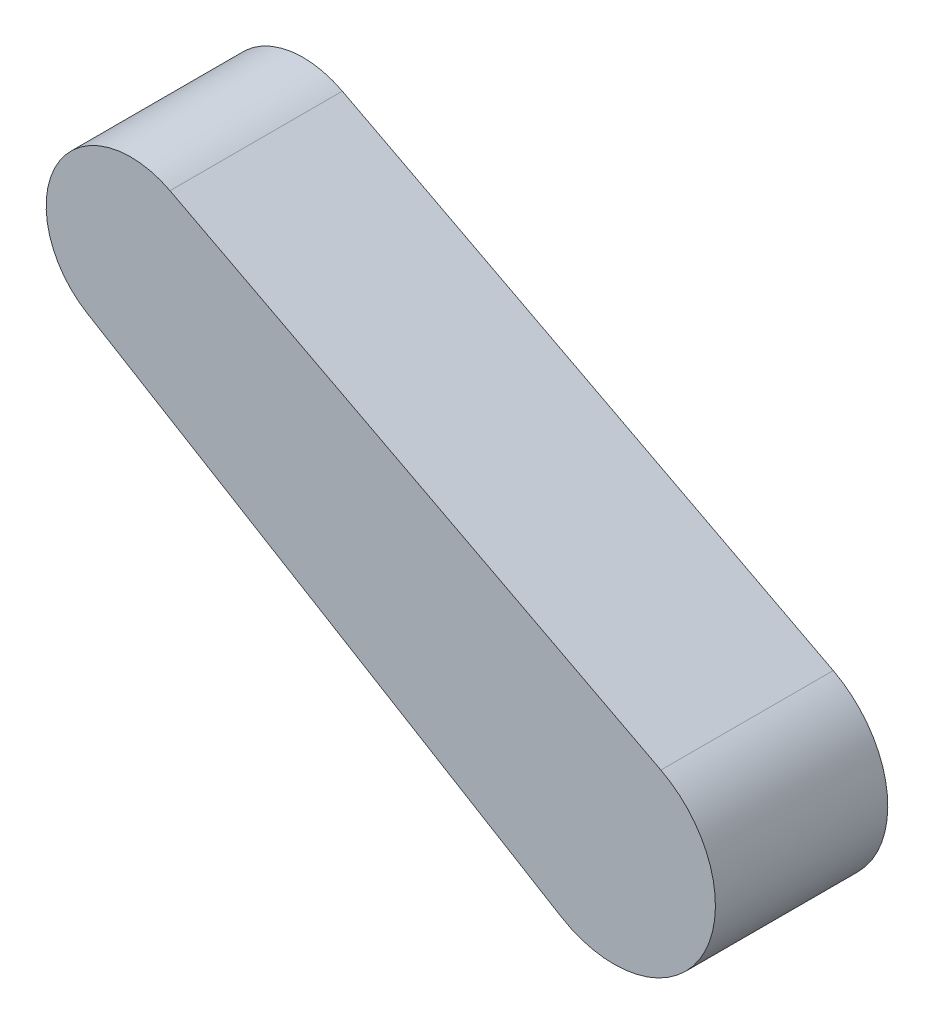
from build123d import *

# Parameters (mm, degrees)
BOSS_EXTRUDE1_DEPTH = 142.24


with BuildPart() as part:
    # Sketch1 → Boss-Extrude1 (new body)
    with BuildSketch(Plane.XY):
        with BuildLine():
            Line((-1543.642727163, 416.47859059), (-1152.2327902, 180.607989738))
            ThreePointArc((-1152.2327902, 180.607989738), (-1035.889227997, 211.350701294), (-1070.172527037, 326.700578567))
            Line((-1070.172527037, 326.700578567), (-1475.259174527, 538.222414615))
            ThreePointArc((-1475.259174527, 538.222414615), (-1568.490455084, 510.513014772), (-1543.642727163, 416.47859059))
        make_face()
    extrude(amount=-BOSS_EXTRUDE1_DEPTH)


solid = part.part
